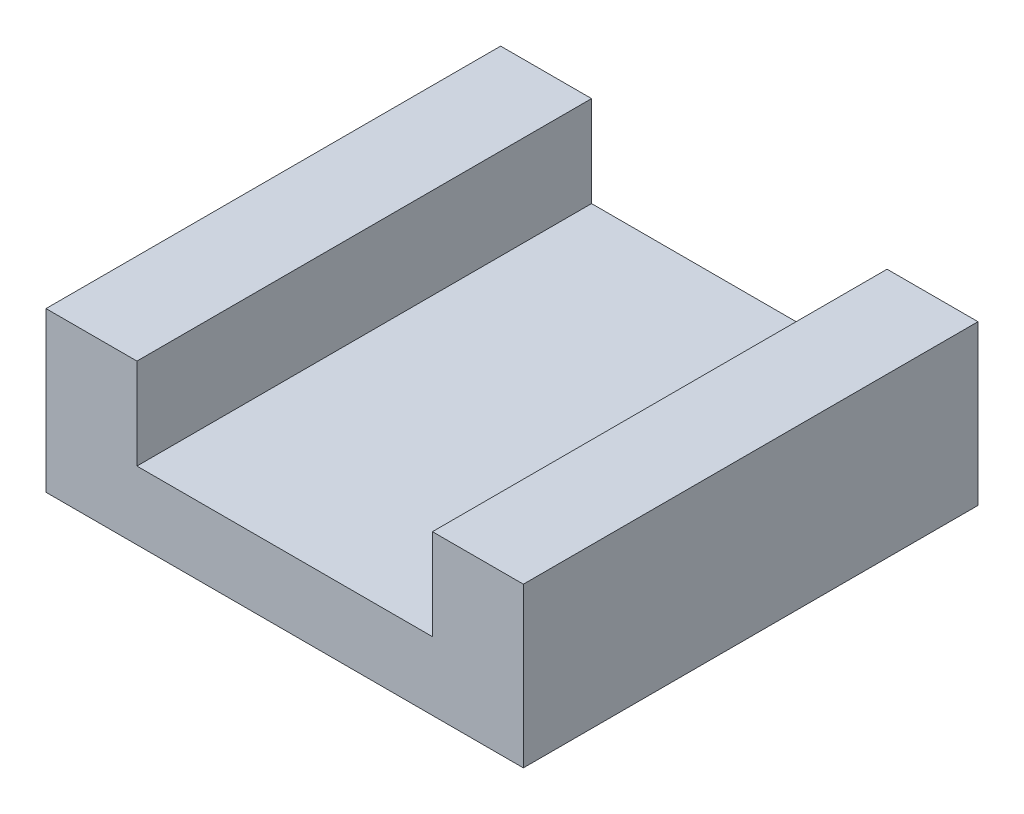
from build123d import *

# Parameters (mm, degrees)
EXTRUDE_1_DEPTH = 10


with BuildPart() as part:
    # 草圖1 → 填料-伸長1 (new body)
    with BuildSketch(Plane.XY):
        Polygon((3.25, 3.5), (5.25, 3.5), (5.25, 0), (-5.25, 0), (-5.25, 3.5), (-3.25, 3.5), (-3.25, 1.5), (3.25, 1.5), align=None)
    extrude(amount=EXTRUDE_1_DEPTH)


solid = part.part
